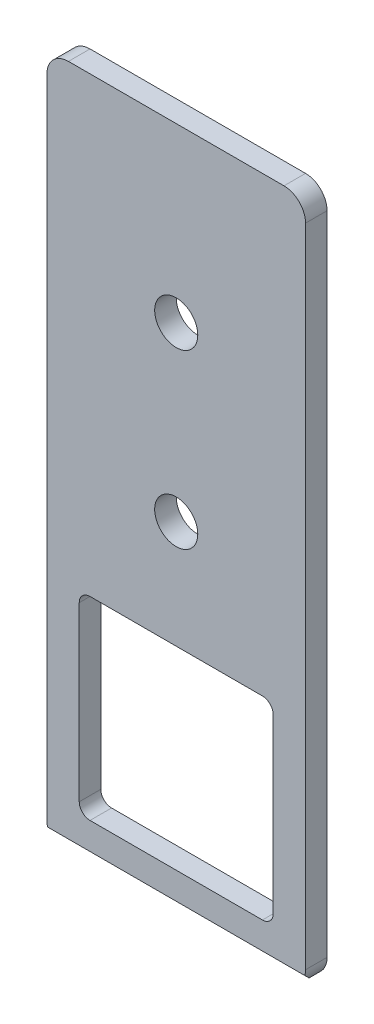
from build123d import *

# Parameters (mm, degrees)
SKETCH1_R           = 3.175
BOSS_EXTRUDE1_DEPTH = 3.175
CUT_EXTRUDE1_DEPTH  = 85.471


with BuildPart() as part:
    # Sketch1 → Boss-Extrude1 (new body)
    with BuildSketch(Plane.XY):
        with BuildLine():
            Line((3.175, 0), (34.925, 0))
            ThreePointArc((34.925, 0), (37.17006403, 0.92993597), (38.1, 3.175))
            Line((38.1, 3.175), (38.1, 98.425))
            ThreePointArc((38.1, 98.425), (37.17006403, 100.67006403), (34.925, 101.6))
            Line((34.925, 101.6), (3.175, 101.6))
            ThreePointArc((3.175, 101.6), (0.92993597, 100.67006403), (0, 98.425))
            Line((0, 98.425), (0, 3.175))
            ThreePointArc((0, 3.175), (0.92993597, 0.92993597), (3.175, 0))
        make_face()
        with Locations((19.05, 50.8)):
            Circle(SKETCH1_R, mode=Mode.SUBTRACT)
        with Locations((19.05, 76.2)):
            Circle(SKETCH1_R, mode=Mode.SUBTRACT)
        with BuildLine():
            Line((6.35, 6.35), (31.75, 6.35))
            ThreePointArc((31.75, 6.35), (32.872532015, 6.814967985), (33.3375, 7.9375))
            Line((33.3375, 7.9375), (33.3375, 33.3375))
            ThreePointArc((33.3375, 33.3375), (32.872532015, 34.460032015), (31.75, 34.925))
            Line((31.75, 34.925), (6.35, 34.925))
            ThreePointArc((6.35, 34.925), (5.227467985, 34.460032015), (4.7625, 33.3375))
            Line((4.7625, 33.3375), (4.7625, 7.9375))
            ThreePointArc((4.7625, 7.9375), (5.227467985, 6.814967985), (6.35, 6.35))
        make_face(mode=Mode.SUBTRACT)
    extrude(amount=BOSS_EXTRUDE1_DEPTH)

    # Sketch2 → Cut-Extrude1 (cut)
    with BuildSketch(Plane.ZY):
        Polygon((0.79375, 0), (3.175, 2.38125), (3.175, 0), align=None)
    extrude(amount=-CUT_EXTRUDE1_DEPTH, mode=Mode.SUBTRACT)


solid = part.part
